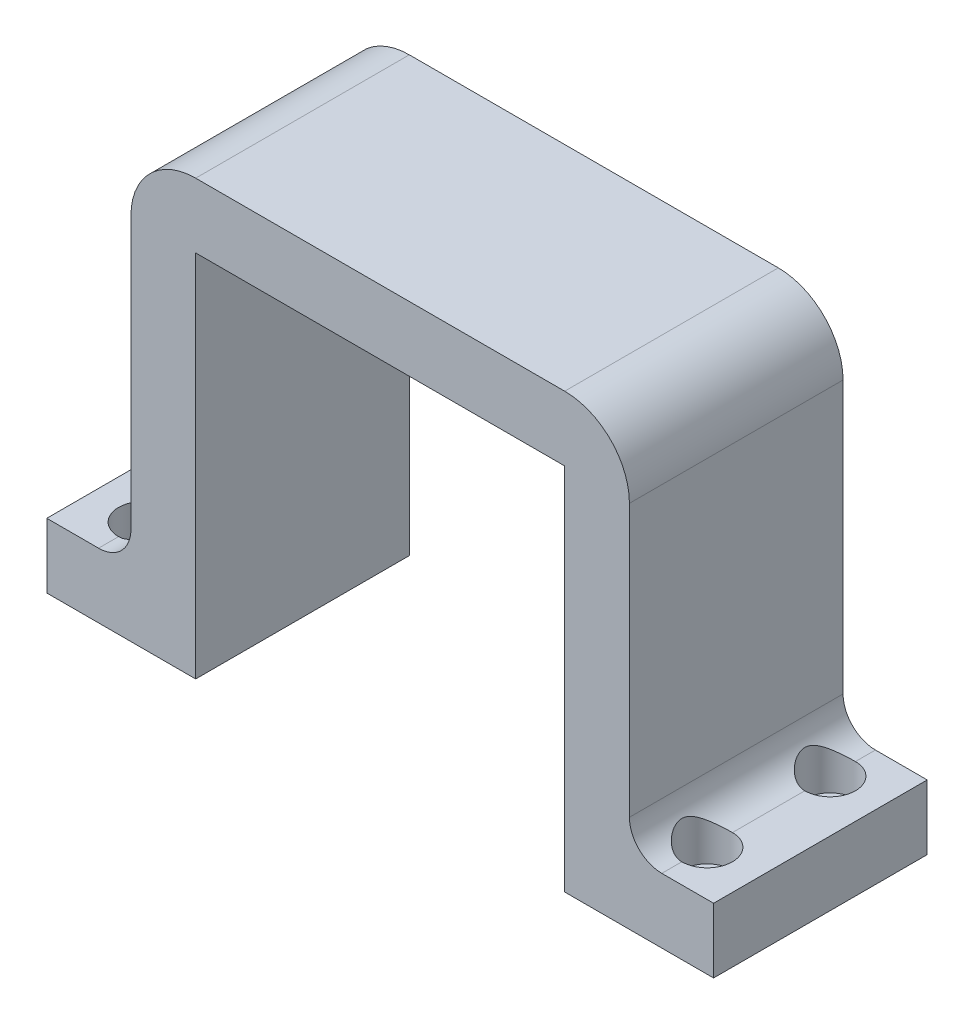
from build123d import *

# Parameters (mm, degrees)
EXTRUDE_THIN1_DEPTH = 33
SKETCH2_W           = 8
SKETCH2_H           = 10
BOSS_EXTRUDE2_DEPTH = 33
FILLET1_R           = 10
FILLET2_R           = 5
SKETCH3_R           = 2
CUT_EXTRUDE1_DEPTH  = 68
SKETCH5_R           = 3.9116
CUT_EXTRUDE2_DEPTH  = 62


with BuildPart() as part:
    # Sketch1 → Extrude-Thin1 (new body)
    with BuildSketch(Plane.XY):
        Polygon((0, 0), (15, 0), (15, 57), (72, 57), (72, 0), (87, 0), (87, 10), (82, 10), (82, 67), (5, 67), (5, 10), (0, 10), align=None)
    extrude(amount=EXTRUDE_THIN1_DEPTH)

    # Sketch2 → Boss-Extrude2 (add, through all)
    with BuildSketch(Plane.XY.offset(33)):
        with Locations((-4, 5)):
            Rectangle(SKETCH2_W, SKETCH2_H)
        with Locations((91, 5)):
            Rectangle(SKETCH2_W, SKETCH2_H)
    extrude(amount=-BOSS_EXTRUDE2_DEPTH)

    # Fillet1
    fillet1_edges = [part.edges().sort_by_distance(p)[0] for p in [
        (5, 67, 16.5),
        (82, 67, 16.5),
    ]]
    fillet(fillet1_edges, radius=FILLET1_R)

    # Fillet2
    fillet2_edges = [part.edges().sort_by_distance(p)[0] for p in [
        (5, 10, 16.5),
        (82, 10, 16.5),
    ]]
    fillet(fillet2_edges, radius=FILLET2_R)

    # Sketch3 → Cut-Extrude1 (cut, through all)
    with BuildSketch(Plane.XZ):
        with Locations((0, 26)):
            Circle(SKETCH3_R)
        with Locations((0, 7)):
            Circle(SKETCH3_R)
        with Locations((87, 26)):
            Circle(SKETCH3_R)
        with Locations((87, 7)):
            Circle(SKETCH3_R)
    extrude(amount=-CUT_EXTRUDE1_DEPTH, mode=Mode.SUBTRACT)

    # Sketch5 → Cut-Extrude2 (cut)
    with BuildSketch(Plane(origin=(0, 67, 0), x_dir=(1, 0, 0), z_dir=(0, 1, 0))):
        with Locations((0, -7)):
            Circle(SKETCH5_R)
        with Locations((0, -26)):
            Circle(SKETCH5_R)
        with Locations((87, -26)):
            Circle(SKETCH5_R)
        with Locations((87, -7)):
            Circle(SKETCH5_R)
    extrude(amount=-CUT_EXTRUDE2_DEPTH, mode=Mode.SUBTRACT)


solid = part.part
